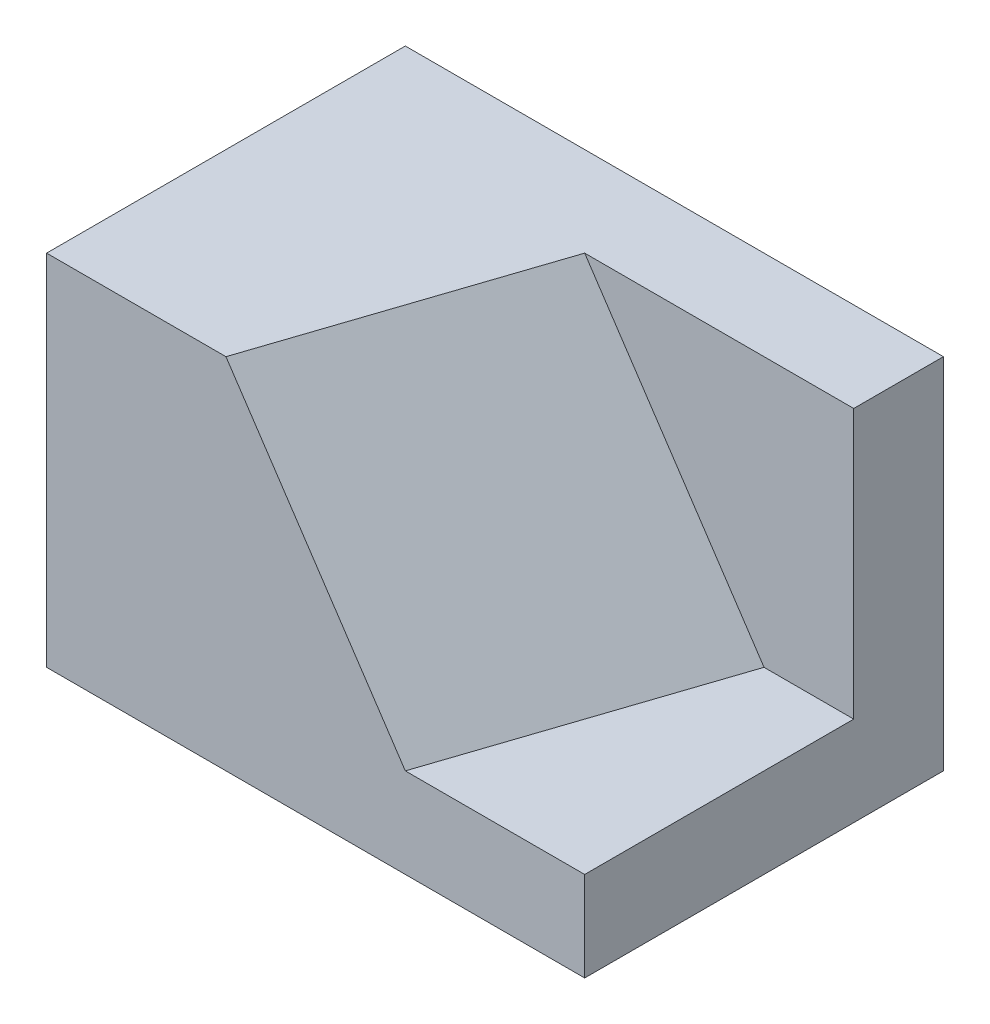
from build123d import *

# Parameters (mm, degrees)
SKETCH_1_W          = 30
SKETCH_1_H          = 20
EXTRUDE_1_DEPTH     = 20
CUT_EXTRUDE_3_REACH = 39.417
SKETCH_5_W          = 15
SKETCH_5_H          = 15
SCALE_1_SCALE       = 0.2


with BuildPart() as part:
    # 草圖1 → 填料-伸長1 (new body)
    with BuildSketch(Plane(origin=(0, 0, 0), x_dir=(1, 0, 0), z_dir=(0, 1, 0))):
        Rectangle(SKETCH_1_W, SKETCH_1_H)
    extrude(amount=EXTRUDE_1_DEPTH)

    # 除料-伸長3: up to this plane
    cut_extrude_3_end = Plane(origin=(7.5, 5, 2.5), z_dir=(-0.8017837257372732, -0.5345224838248487, -0.2672612419124243))
    # 草圖5 → 除料-伸長3 (cut, up to the surface)
    with BuildSketch(Plane(origin=(15, 0, 0), x_dir=(0, 0, -1), z_dir=(1, 0, 0)), mode=Mode.PRIVATE) as cut_extrude_3_sk1:
        with Locations((-2.5, 12.5)):
            Rectangle(SKETCH_5_W, SKETCH_5_H)
    cut_extrude_3_tool1 = split(extrude(cut_extrude_3_sk1.sketch, amount=-CUT_EXTRUDE_3_REACH, mode=Mode.PRIVATE), bisect_by=cut_extrude_3_end, keep=Keep.BOTH, mode=Mode.PRIVATE)
    add(cut_extrude_3_tool1.solids().sort_by_distance((15, 12.5, 2.5))[0], mode=Mode.SUBTRACT)


with BuildPart() as part_1:
    # 縮放比例1: scaled about (-2.551020408, 8.928571429, -0.918367347)
    add(part.part.scale(SCALE_1_SCALE).moved(Location((-2.040816326, 7.142857143, -0.734693878))))


solid = part_1.part
